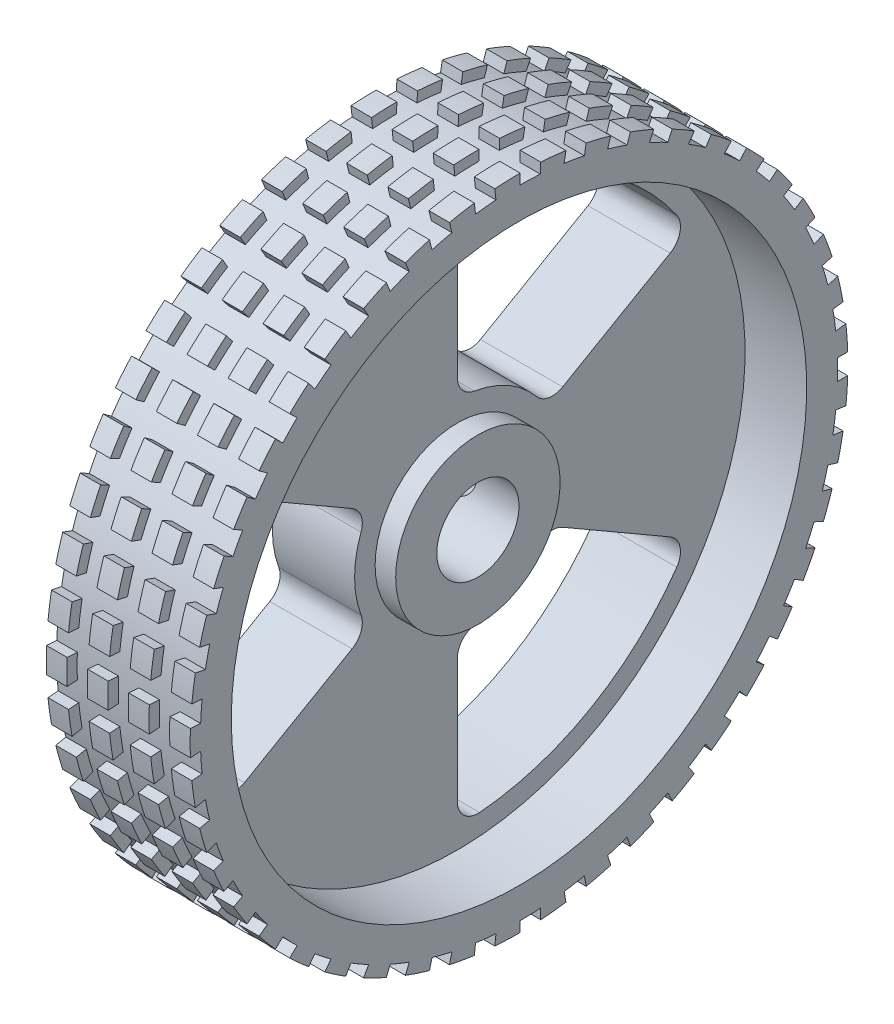
from build123d import *

# Parameters (mm, degrees)
CUT_EXTRUDE1_DEPTH       = 5.0000001
FILLET1_R                = 1
FILLET2_R                = 1
FILLET3_R                = 1
FILLET4_R                = 1
CIRPATTERN1_COUNT        = 3
FILLET1_OF_CIRPATTERN1_R = 1
FILLET2_OF_CIRPATTERN1_R = 1
FILLET3_OF_CIRPATTERN1_R = 1
FILLET4_OF_CIRPATTERN1_R = 1
SKETCH5_W                = 1
SKETCH5_H                = 0.5
CUT_EXTRUDE2_DEPTH       = 8.0000001
LPATTERN1_COUNT          = 3
LPATTERN1_PITCH          = 2
CIRPATTERN2_COUNT        = 45


with BuildPart() as part:
    # Sketch1 → Revolve1 (revolve)
    with BuildSketch(Plane.XY):
        Polygon((0, 16), (0, 2), (5, 2), (5, 4), (4, 4), (4, 14), (7, 14), (7, 16), align=None)
    revolve(axis=Axis((0, 0, 0), (1, 0, 0)))

    # Sketch3 → Cut-Revolve1 (revolve, cut)
    with BuildSketch(Plane(origin=(0, 0, 0), x_dir=(1, 0, 0), z_dir=(0, 1, 0))):
        Polygon((2, 0), (2, 16), (3.5, 16), (3.5, 11.5), (2.9, 11.5), (2.9, 0), align=None)
    revolve(axis=Axis((2, 0, 0), (0, 0, -1)), mode=Mode.SUBTRACT)

    # Sketch4 → Cut-Extrude1 (cut, through all)
    with BuildSketch(Plane(origin=(4, 0, 0), x_dir=(0, 0, -1), z_dir=(1, 0, 0))):
        with BuildLine():
            Line((0, 13), (0, 5))
            ThreePointArc((0, 5), (2.5, 4.330127019), (4.330127019, 2.5))
            Line((4.330127019, 2.5), (11.258330249, 6.5))
            ThreePointArc((11.258330249, 6.5), (6.5, 11.258330249), (0, 13))
        make_face()
    cut_extrude1 = extrude(amount=-CUT_EXTRUDE1_DEPTH, mode=Mode.SUBTRACT)

    # Fillet1
    fillet1_edges = [part.edges().sort_by_distance(p)[0] for p in [
        (2, 2.5, -4.330127019),
    ]]
    fillet(fillet1_edges, radius=FILLET1_R)

    # Fillet2
    fillet2_edges = [part.edges().sort_by_distance(p)[0] for p in [
        (2, 5, 0),
    ]]
    fillet(fillet2_edges, radius=FILLET2_R)

    # Fillet3
    fillet3_edges = [part.edges().sort_by_distance(p)[0] for p in [
        (2, 6.5, -11.258330249),
    ]]
    fillet(fillet3_edges, radius=FILLET3_R)

    # Fillet4
    fillet4_edges = [part.edges().sort_by_distance(p)[0] for p in [
        (2, 13, 0),
    ]]
    fillet(fillet4_edges, radius=FILLET4_R)

    # CirPattern1: Cut-Extrude1 ×3 about axis
    cirpattern1_axis = Axis((0, 0, 0), (1, 0, 0))
    for i in range(1, CIRPATTERN1_COUNT):
        add(cut_extrude1.rotate(cirpattern1_axis, i * 360 / CIRPATTERN1_COUNT), mode=Mode.SUBTRACT)

    # Fillet1 of CirPattern1
    fillet1_of_cirpattern1_edges = [part.edges().sort_by_distance(p)[0] for p in [
        (2, 2.5, 4.330127019),
        (2, -5, 0),
    ]]
    fillet(fillet1_of_cirpattern1_edges, radius=FILLET1_OF_CIRPATTERN1_R)

    # Fillet2 of CirPattern1
    fillet2_of_cirpattern1_edges = [part.edges().sort_by_distance(p)[0] for p in [
        (2, -2.5, 4.330127019),
        (2, -2.5, -4.330127019),
    ]]
    fillet(fillet2_of_cirpattern1_edges, radius=FILLET2_OF_CIRPATTERN1_R)

    # Fillet3 of CirPattern1
    fillet3_of_cirpattern1_edges = [part.edges().sort_by_distance(p)[0] for p in [
        (2, 6.5, 11.258330249),
        (2, -13, 0),
    ]]
    fillet(fillet3_of_cirpattern1_edges, radius=FILLET3_OF_CIRPATTERN1_R)

    # Fillet4 of CirPattern1
    fillet4_of_cirpattern1_edges = [part.edges().sort_by_distance(p)[0] for p in [
        (2, -6.5, 11.258330249),
        (2, -6.5, -11.258330249),
    ]]
    fillet(fillet4_of_cirpattern1_edges, radius=FILLET4_OF_CIRPATTERN1_R)

    # Sketch5 → Cut-Revolve2 (revolve, cut)
    with BuildSketch(Plane.XY):
        with Locations((5.5, 15.75)):
            Rectangle(SKETCH5_W, SKETCH5_H)
    cut_revolve2 = revolve(axis=Axis((0, 0, 0), (1, 0, 0)), mode=Mode.SUBTRACT)

    # Sketch6 → Cut-Extrude2 (cut, through all)
    with BuildSketch(Plane(origin=(7, 0, 0), x_dir=(0, 0, -1), z_dir=(1, 0, 0))):
        with BuildLine():
            Line((15.992185592, 0.5), (15.491933385, 0.5))
            ThreePointArc((15.491933385, 0.5), (15.5, 0), (15.491933385, -0.5))
            Line((15.491933385, -0.5), (15.992185592, -0.5))
            ThreePointArc((15.992185592, -0.5), (16, 0), (15.992185592, 0.5))
        make_face()
    cut_extrude2 = extrude(amount=-CUT_EXTRUDE2_DEPTH, mode=Mode.SUBTRACT)

    # LPattern1: Cut-Revolve2 ×3
    with Locations(*[(-i * LPATTERN1_PITCH, 0, 0) for i in range(1, LPATTERN1_COUNT)]):
        add(cut_revolve2, mode=Mode.SUBTRACT)

    # CirPattern2: Cut-Extrude2 ×45 about axis
    cirpattern2_axis = Axis((0, 0, 0), (1, 0, 0))
    for i in range(1, CIRPATTERN2_COUNT):
        add(cut_extrude2.rotate(cirpattern2_axis, i * 360 / CIRPATTERN2_COUNT), mode=Mode.SUBTRACT)


solid = part.part
